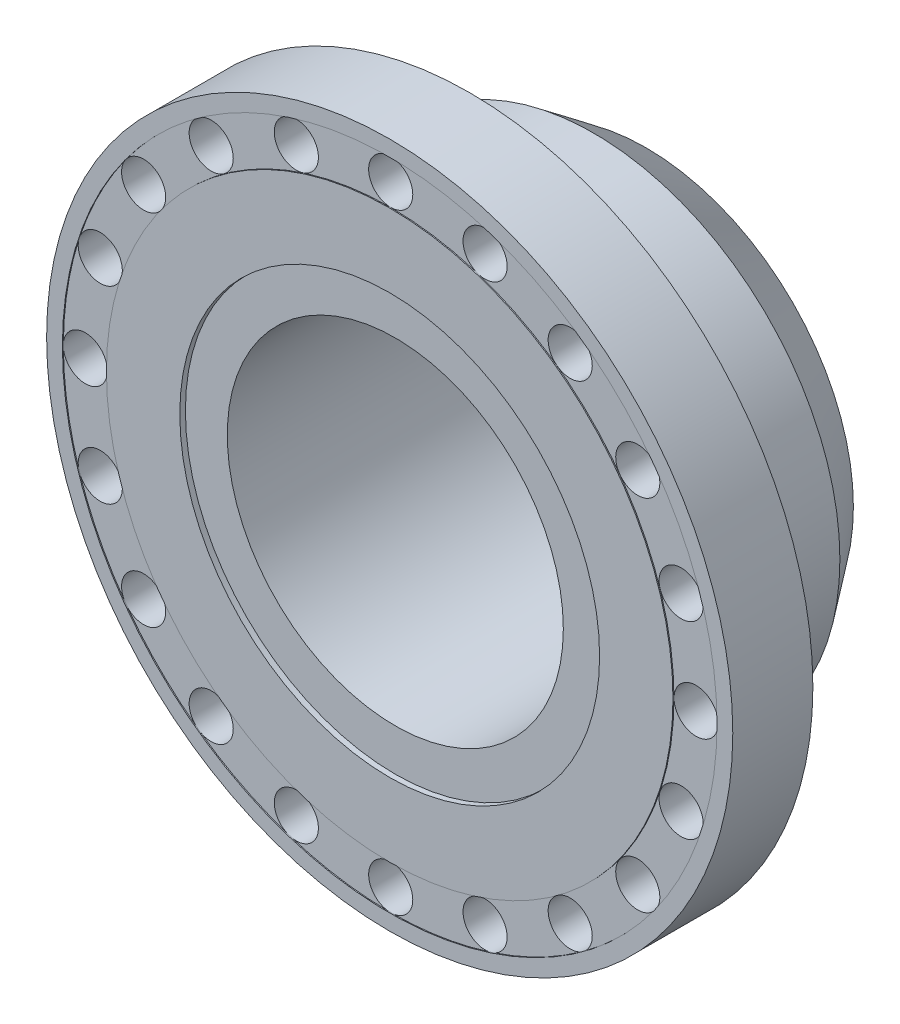
from build123d import *

# Parameters (mm, degrees)
SKETCH1_R         = 456.61961
EXTRUDE1_DEPTH    = 106.59872
SKETCH2_R         = 279.38095
EXTRUDE2_DEPTH    = 7.46506
SKETCH3_R         = 327.70064
EXTRUDE3_DEPTH    = 234.73156
CHAMFER1_SIZE     = 69.85
CHAMFER1_SIZE2    = 51.89601
SKETCH4_R         = 223.63049
EXTRUDE4_DEPTH    = 333.86522
SKETCH5_R         = 435.62778
SKETCH5_R_2       = 377.02109
EXTRUDE5_DEPTH    = 1.34493
SKETCH6_R         = 29.36875
EXTRUDE6_DEPTH    = 105.71734
CIRPATTERN1_COUNT = 20
CHAMFER2_SIZE     = 6.35


with BuildPart() as part:
    # Sketch1 → Extrude1 (new body)
    with BuildSketch(Plane.XY):
        Circle(SKETCH1_R)
    extrude(amount=-EXTRUDE1_DEPTH)

    # Sketch2 → Extrude2 (cut)
    with BuildSketch(Plane.XY):
        Circle(SKETCH2_R)
    extrude(amount=-EXTRUDE2_DEPTH, mode=Mode.SUBTRACT)

    # Sketch3 → Extrude3 (add)
    with BuildSketch(Plane(origin=(0, 0, -106.59872), x_dir=(-1, 0, 0), z_dir=(0, 0, -1))):
        Circle(SKETCH3_R)
    extrude(amount=EXTRUDE3_DEPTH)

    # Chamfer1
    chamfer1_edges = [part.edges().sort_by_distance(p)[0] for p in [
        (327.70064, 0, -341.33028),
    ]]
    chamfer1_side = [part.faces().sort_by_distance(p)[0] for p in [
        (327.70064, 0, -223.9645),
    ]]
    chamfer(chamfer1_edges, length=CHAMFER1_SIZE, length2=CHAMFER1_SIZE2, reference=chamfer1_side[0])

    # Sketch4 → Extrude4 (cut)
    with BuildSketch(Plane.XY.offset(-7.46506)):
        Circle(SKETCH4_R)
    extrude(amount=-EXTRUDE4_DEPTH, mode=Mode.SUBTRACT)

    # Sketch5 → Extrude5 (cut)
    with BuildSketch(Plane.XY):
        Circle(SKETCH5_R)
        Circle(SKETCH5_R_2, mode=Mode.SUBTRACT)
    extrude(amount=-EXTRUDE5_DEPTH, mode=Mode.SUBTRACT)

    # Sketch6 → Extrude6 (cut)
    with BuildSketch(Plane.XY.offset(-1.34493)):
        with Locations((0, 406.44191)):
            Circle(SKETCH6_R)
    extrude6 = extrude(amount=-EXTRUDE6_DEPTH, mode=Mode.SUBTRACT)

    # CirPattern1: Extrude6 ×20 about axis
    cirpattern1_axis = Axis((0, 0, 0), (0, 0, 1))
    for i in range(1, CIRPATTERN1_COUNT):
        add(extrude6.rotate(cirpattern1_axis, i * 360 / CIRPATTERN1_COUNT), mode=Mode.SUBTRACT)

    # Chamfer2
    chamfer2_edges = [part.edges().sort_by_distance(p)[0] for p in [
        (-223.63049, 0, -341.33028),
    ]]
    chamfer(chamfer2_edges, length=CHAMFER2_SIZE)


solid = part.part
